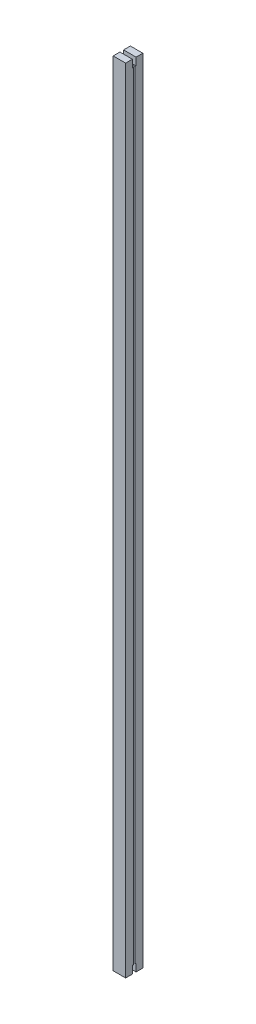
from build123d import *

# Parameters (mm, degrees)
EXTRUDE_1_DEPTH     = 1383.55
SKETCH_2_W          = 6.397518836
SKETCH_2_H          = 13.287823591
CUT_EXTRUDE_1_DEPTH = 22.764865627


with BuildPart() as part:
    # Эскиз1 → Бобышка-Вытянуть1 (new body)
    with BuildSketch(Plane(origin=(0, 0, 0), x_dir=(1, 0, 0), z_dir=(0, 1, 0))):
        Polygon((-11.764865627, 15), (10, 15), (10, 1.25), (6, 1.25), (6, -1.25), (10, -1.25), (10, -15), (-11.764865627, -15), align=None)
    extrude(amount=EXTRUDE_1_DEPTH)

    # Эскиз2 → Вырез-Вытянуть1 (cut, through all)
    with BuildSketch(Plane.ZY.offset(11.764865627)):
        with Locations((0, 6.643911796)):
            Rectangle(SKETCH_2_W, SKETCH_2_H)
        with Locations((0, 1376.906088205)):
            Rectangle(SKETCH_2_W, SKETCH_2_H)
    extrude(amount=-CUT_EXTRUDE_1_DEPTH, mode=Mode.SUBTRACT)


solid = part.part
